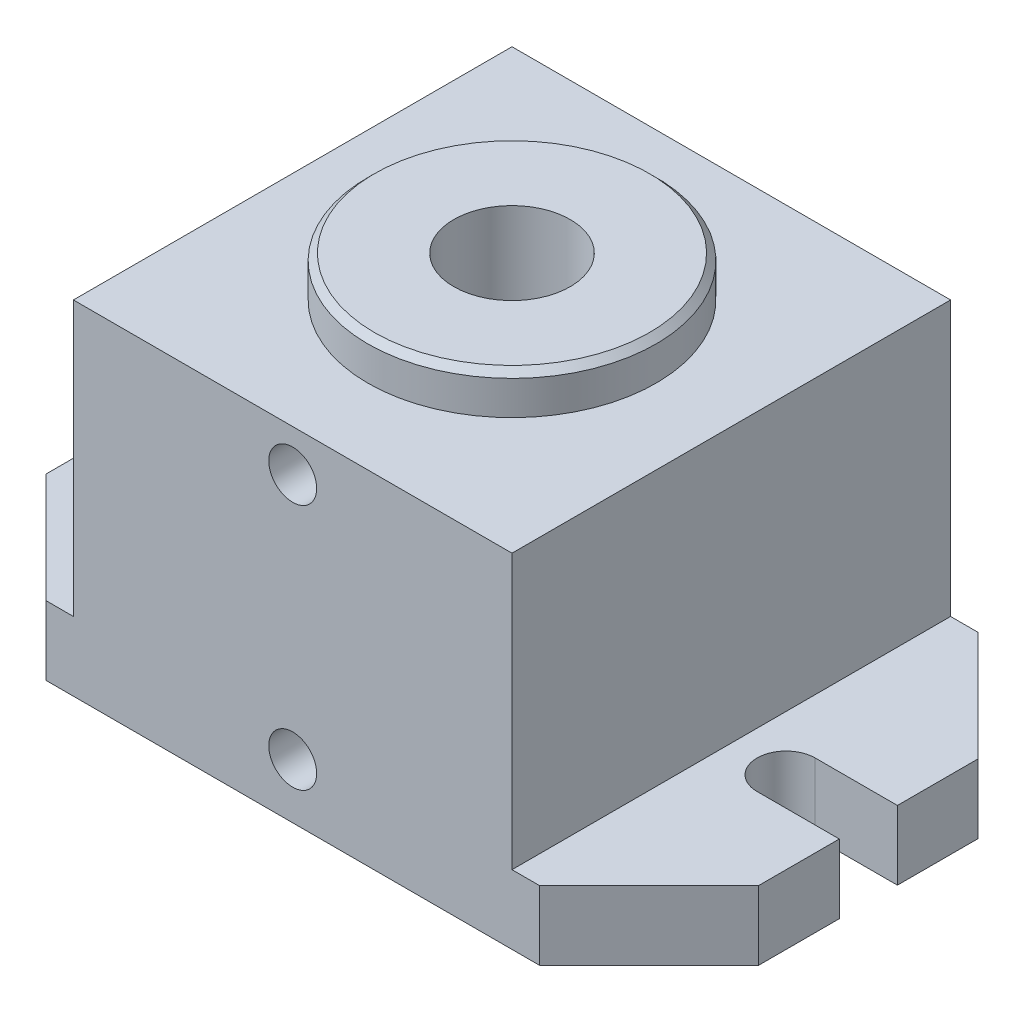
from build123d import *

# Parameters (mm, degrees)
SKETCH1_W          = 101.6
SKETCH1_H          = 101.6
EXTRUDE1_DEPTH     = 79.502
SKETCH2_R          = 33.401
EXTRUDE2_DEPTH     = 9.398
CHAMFER1_SIZE      = 1.524
SKETCH3_R          = 13.4874
CUT_EXTRUDE1_DEPTH = 89.9
EXTRUDE3_DEPTH     = 16.002
CHAMFER2_SIZE      = 25.4
SKETCH8_R          = 5.5499
CUT_EXTRUDE3_DEPTH = 12.7


with BuildPart() as part:
    # Sketch1 → Extrude1 (new body)
    with BuildSketch(Plane(origin=(0, 0, 0), x_dir=(1, 0, 0), z_dir=(0, 1, 0))):
        Rectangle(SKETCH1_W, SKETCH1_H)
    extrude(amount=EXTRUDE1_DEPTH)

    # Sketch2 → Extrude2 (add)
    with BuildSketch(Plane(origin=(0, 79.502, 0), x_dir=(-1, 0, 0), z_dir=(0, 1, 0))):
        with Locations(Location((0, 0, 0), (0, 0, 90))):  # turned: the seam where the file's is
            Circle(SKETCH2_R)
    extrude(amount=EXTRUDE2_DEPTH)

    # Chamfer1
    chamfer1_edges = [part.edges().sort_by_distance(p)[0] for p in [
        (0, 88.9, -33.401),
    ]]
    chamfer(chamfer1_edges, length=CHAMFER1_SIZE)

    # Sketch3 → Cut-Extrude1 (cut, through all)
    with BuildSketch(Plane(origin=(0, 88.9, 0), x_dir=(1, 0, 0), z_dir=(0, 1, 0))):
        with Locations(Location((0, 0, 0), (0, 0, 270))):  # turned: the seam where the file's is
            Circle(SKETCH3_R)
    extrude(amount=-CUT_EXTRUDE1_DEPTH, mode=Mode.SUBTRACT)

    # Sketch7 → Extrude3 (add)
    with BuildSketch(Plane.XZ):
        with BuildLine():
            Line((50.8, 50.8), (82.55, 50.8))
            Line((82.55, 50.8), (82.55, 6.731))
            Line((82.55, 6.731), (63.5, 6.731))
            ThreePointArc((63.5, 6.731), (56.769, 0), (63.5, -6.731))
            Line((63.5, -6.731), (82.55, -6.731))
            Line((82.55, -6.731), (82.55, -50.8))
            Line((82.55, -50.8), (50.8, -50.8))
            Line((50.8, -50.8), (50.8, 50.8))
        make_face()
        with BuildLine():
            Line((-82.55, -6.731), (-82.55, -50.8))
            Line((-82.55, -50.8), (-50.8, -50.8))
            Line((-50.8, -50.8), (-50.8, 50.8))
            Line((-50.8, 50.8), (-82.55, 50.8))
            Line((-82.55, 50.8), (-82.55, 6.731))
            Line((-82.55, 6.731), (-63.5, 6.731))
            ThreePointArc((-63.5, 6.731), (-56.769, 0), (-63.5, -6.731))
            Line((-63.5, -6.731), (-82.55, -6.731))
        make_face()
    extrude(amount=-EXTRUDE3_DEPTH)

    # Chamfer2
    chamfer2_edges = [part.edges().sort_by_distance(p)[0] for p in [
        (-82.55, 8.001, -50.8),
        (82.55, 8.001, -50.8),
        (82.55, 8.001, 50.8),
        (-82.55, 8.001, 50.8),
    ]]
    chamfer(chamfer2_edges, length=CHAMFER2_SIZE)

    # Sketch8 → Cut-Extrude3 (cut)
    with BuildSketch(Plane.XY.offset(50.8)):
        with Locations((0, 69.85)):
            Circle(SKETCH8_R)
        with Locations((0, 12.7)):
            Circle(SKETCH8_R)
    extrude(amount=-CUT_EXTRUDE3_DEPTH, mode=Mode.SUBTRACT)


solid = part.part
